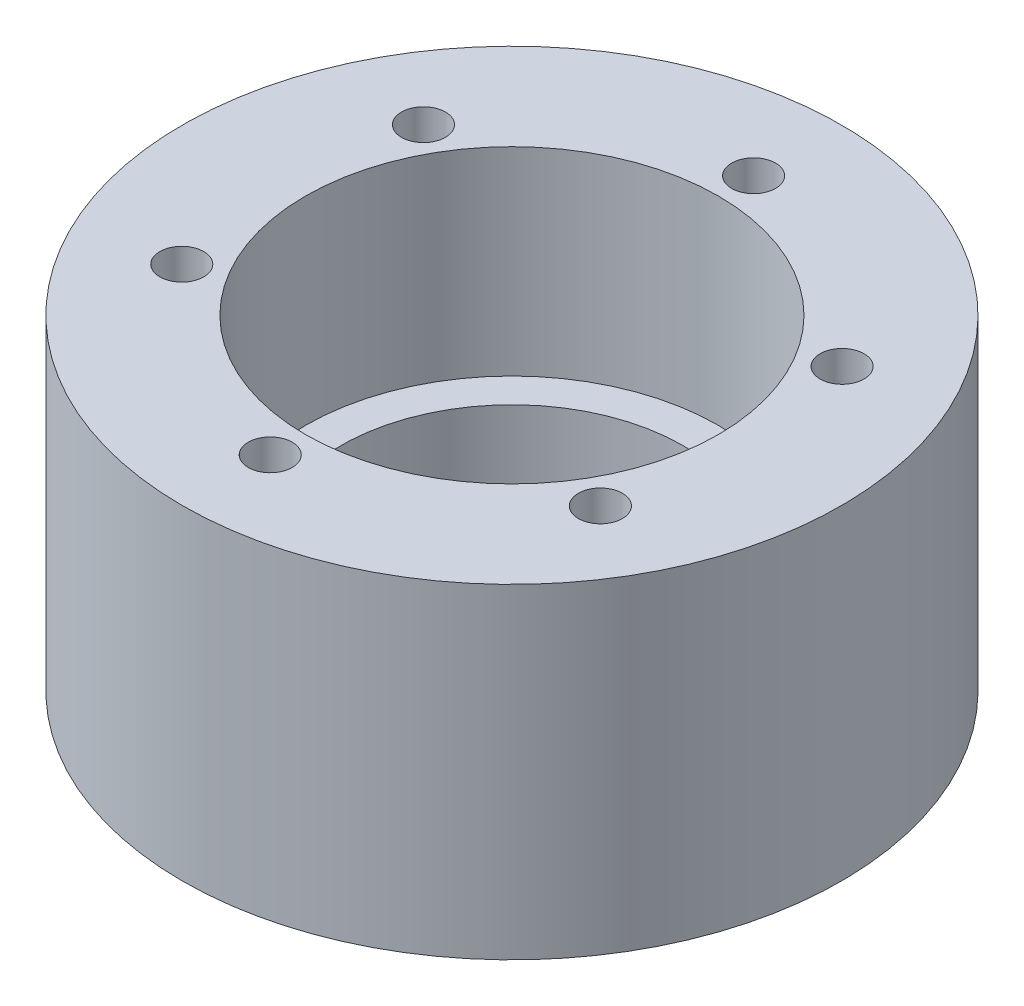
from build123d import *

# Parameters (mm, degrees)
SKETCH1_R                       = 37.5
BOSS_EXTRUDE1_DEPTH             = 37
SKETCH2_R                       = 23.5
CUT_EXTRUDE1_DEPTH              = 22.6
SKETCH3_R                       = 19.5
CUT_EXTRUDE2_DEPTH              = 38
M6X1_0_TAPPED_HOLE1_D           = 5
M6X1_0_TAPPED_HOLE1_DEPTH       = 16
M6X1_0_TAPPED_HOLE1_TIP         = 1.502151548
TAP_DRILL_FOR_M6X1_0_TAP1_D     = 5
TAP_DRILL_FOR_M6X1_0_TAP1_DEPTH = 16
TAP_DRILL_FOR_M6X1_0_TAP1_TIP   = 1.502151548


with BuildPart() as part:
    # Sketch1 → Boss-Extrude1 (new body)
    with BuildSketch(Plane(origin=(0, 0, 0), x_dir=(1, 0, 0), z_dir=(0, 1, 0))):
        Circle(SKETCH1_R)
    extrude(amount=BOSS_EXTRUDE1_DEPTH)

    # Sketch2 → Cut-Extrude1 (cut)
    with BuildSketch(Plane(origin=(0, 37, 0), x_dir=(1, 0, 0), z_dir=(0, 1, 0))):
        Circle(SKETCH2_R)
    extrude(amount=-CUT_EXTRUDE1_DEPTH, mode=Mode.SUBTRACT)

    # Sketch3 → Cut-Extrude2 (cut, through all)
    with BuildSketch(Plane.XZ):
        Circle(SKETCH3_R)
    extrude(amount=-CUT_EXTRUDE2_DEPTH, mode=Mode.SUBTRACT)

    # M6x1.0 Tapped Hole1
    with Locations(Plane(origin=(0, 0, 31), x_dir=(0, 0, -1), z_dir=(0, -1, 0))):
        with Locations((0, 0), (15.5, 26.846787517), (46.5, 26.846787517), (62, 0), (46.5, -26.846787517), (15.5, -26.846787517)):
            Hole(M6X1_0_TAPPED_HOLE1_D / 2, depth=M6X1_0_TAPPED_HOLE1_DEPTH)
            with Locations((0, 0, -(M6X1_0_TAPPED_HOLE1_DEPTH + M6X1_0_TAPPED_HOLE1_TIP / 2))):  # 118° drill point
                Cone(0, M6X1_0_TAPPED_HOLE1_D / 2, M6X1_0_TAPPED_HOLE1_TIP, mode=Mode.SUBTRACT)

    # Tap Drill for M6x1.0 Tap1
    with Locations(Plane(origin=(0, 37, -27.5), x_dir=(0, 0, 1), z_dir=(0, 1, 0))):
        with Locations((0, 0), (13.75, 23.815698604), (41.25, 23.815698604), (55, 0), (41.25, -23.815698604), (13.75, -23.815698604)):
            Hole(TAP_DRILL_FOR_M6X1_0_TAP1_D / 2, depth=TAP_DRILL_FOR_M6X1_0_TAP1_DEPTH)
            with Locations((0, 0, -(TAP_DRILL_FOR_M6X1_0_TAP1_DEPTH + TAP_DRILL_FOR_M6X1_0_TAP1_TIP / 2))):  # 118° drill point
                Cone(0, TAP_DRILL_FOR_M6X1_0_TAP1_D / 2, TAP_DRILL_FOR_M6X1_0_TAP1_TIP, mode=Mode.SUBTRACT)


solid = part.part
